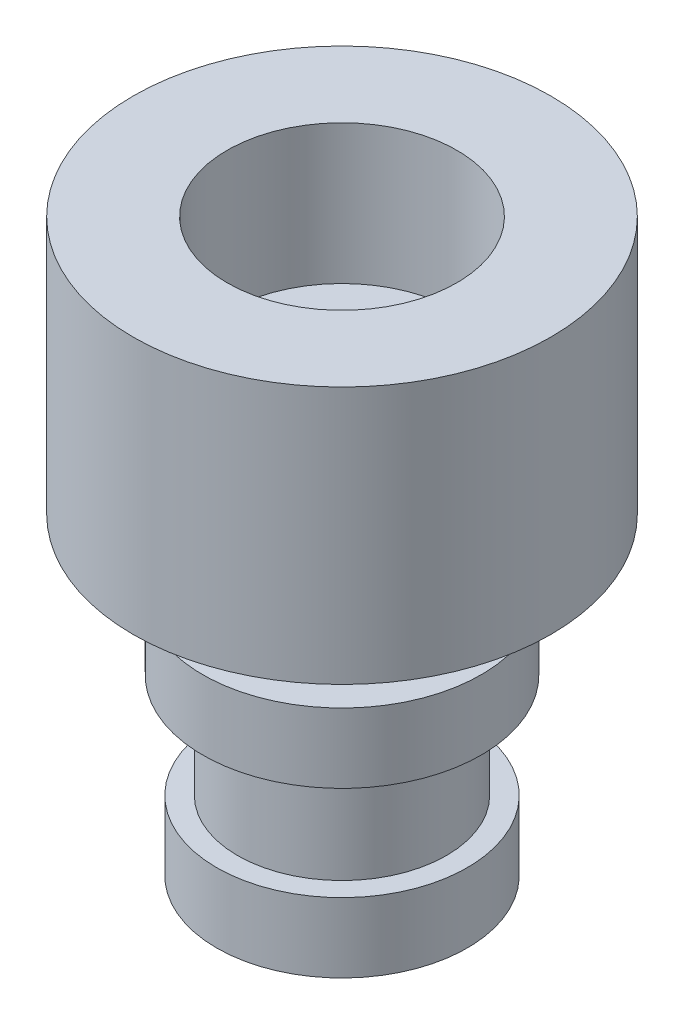
from build123d import *

# Parameters (mm, degrees)
SKETCH1_R           = 3
BOSS_EXTRUDE1_DEPTH = 3.7
SKETCH1_3_R         = 1.6
BOSS_EXTRUDE2_DEPTH = 1
SKETCH5_R           = 1.5
BOSS_EXTRUDE3_DEPTH = 1
SKETCH6_R           = 2
BOSS_EXTRUDE4_DEPTH = 1
SKETCH8_R           = 1.5
BOSS_EXTRUDE5_DEPTH = 2.5
SKETCH10_R          = 1.8
BOSS_EXTRUDE6_DEPTH = 1
SKETCH12_R          = 1.65
CUT_EXTRUDE1_DEPTH  = 2


with BuildPart() as part:
    # Sketch1 → Boss-Extrude1 (new body)
    with BuildSketch(Plane(origin=(0, 0, 0), x_dir=(1, 0, 0), z_dir=(0, 1, 0))):
        with Locations((-0.522013312, 0.511138034)):
            Circle(SKETCH1_R)
    extrude(amount=BOSS_EXTRUDE1_DEPTH)

    # Sketch1_3 → Boss-Extrude2 (add)
    with BuildSketch(Plane(origin=(0, 0, 0), x_dir=(1, 0, 0), z_dir=(0, 1, 0))):
        with Locations((-0.522013312, 0.511138034)):
            Circle(SKETCH1_3_R)
    extrude(amount=BOSS_EXTRUDE2_DEPTH)

    # Sketch5 → Boss-Extrude3 (add)
    with BuildSketch(Plane.XZ):
        with Locations((-0.522013312, -0.511138034)):
            Circle(SKETCH5_R)
    extrude(amount=BOSS_EXTRUDE3_DEPTH)

    # Sketch6 → Boss-Extrude4 (add)
    with BuildSketch(Plane.XZ.offset(1)):
        with Locations((-0.522013312, -0.511138034)):
            Circle(SKETCH6_R)
    extrude(amount=BOSS_EXTRUDE4_DEPTH)

    # Sketch8 → Boss-Extrude5 (add)
    with BuildSketch(Plane(origin=(0, -2, 0), x_dir=(-1, 0, 0), z_dir=(0, -1, 0))):
        with Locations((0.522013312, 0.511138034)):
            Circle(SKETCH8_R)
    extrude(amount=BOSS_EXTRUDE5_DEPTH)

    # Sketch10 → Boss-Extrude6 (add)
    with BuildSketch(Plane.XZ.offset(4.5)):
        with Locations((-0.522013312, -0.511138034)):
            Circle(SKETCH10_R)
    extrude(amount=-BOSS_EXTRUDE6_DEPTH)

    # Sketch12 → Cut-Extrude1 (cut)
    with BuildSketch(Plane(origin=(0, 3.7, 0), x_dir=(1, 0, 0), z_dir=(0, 1, 0))):
        with Locations((-0.522013312, 0.511138034)):
            Circle(SKETCH12_R)
    extrude(amount=-CUT_EXTRUDE1_DEPTH, mode=Mode.SUBTRACT)


solid = part.part
